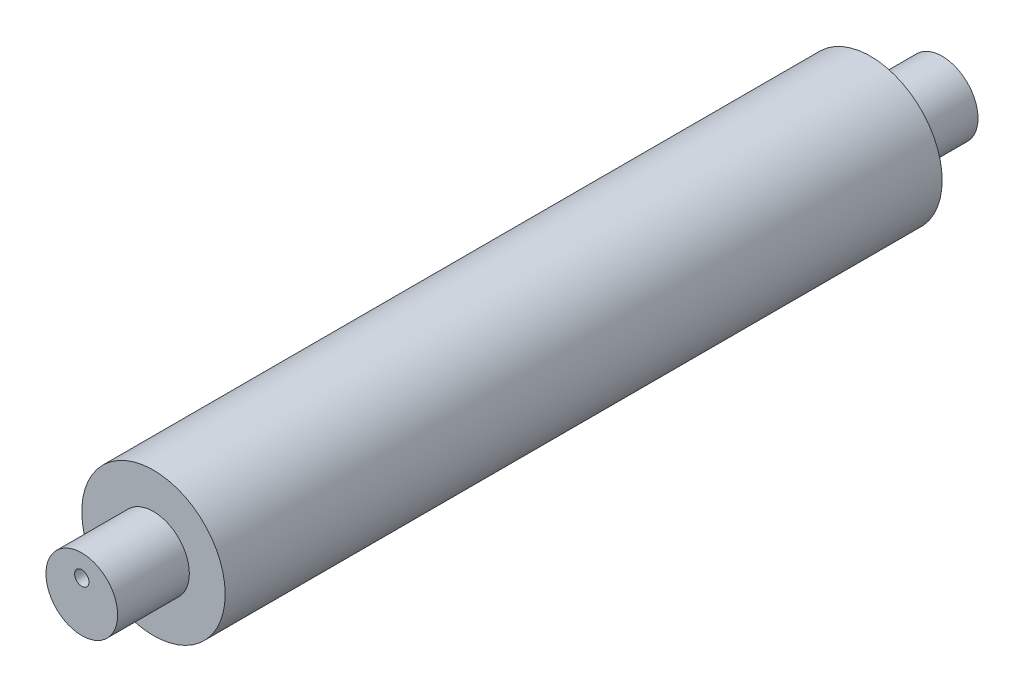
from build123d import *

# Parameters (mm, degrees)
SKETCH9_R           = 25
BOSS_EXTRUDE1_DEPTH = 125
SKETCH10_R          = 12.5
BOSS_EXTRUDE4_DEPTH = 150
SKETCH20_R          = 2.5
CUT_EXTRUDE5_DEPTH  = 20
SKETCH19_R          = 2.5
CUT_EXTRUDE6_DEPTH  = 20


with BuildPart() as part:
    # Sketch9 → Boss-Extrude1 (new body, symmetric)
    with BuildSketch(Plane.XY):
        Circle(SKETCH9_R)
    extrude(amount=BOSS_EXTRUDE1_DEPTH, both=True)

    # Sketch10 → Boss-Extrude4 (add, symmetric)
    with BuildSketch(Plane.XY):
        Circle(SKETCH10_R)
    extrude(amount=BOSS_EXTRUDE4_DEPTH, both=True)

    # Sketch20 → Cut-Extrude5 (cut)
    with BuildSketch(Plane(origin=(0, 0, -150), x_dir=(-1, 0, 0), z_dir=(0, 0, -1))):
        with Locations((0, 4.91077603)):
            Circle(SKETCH20_R)
    extrude(amount=-CUT_EXTRUDE5_DEPTH, mode=Mode.SUBTRACT)

    # Sketch19 → Cut-Extrude6 (cut)
    with BuildSketch(Plane.XY.offset(150)):
        with Locations((0, 4.91077603)):
            Circle(SKETCH19_R)
    extrude(amount=-CUT_EXTRUDE6_DEPTH, mode=Mode.SUBTRACT)


solid = part.part
